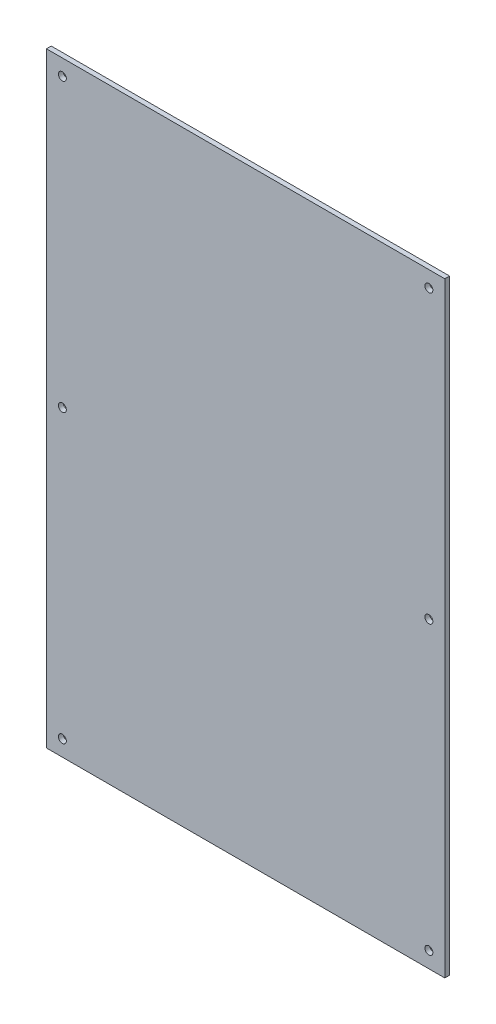
from build123d import *

# Parameters (mm, degrees)
ESQUISSE1_R        = 2.5
BOSS_EXTRU_1_DEPTH = 3


with BuildPart() as part:
    # Esquisse1 → Boss.-Extru.1 (new body)
    with BuildSketch(Plane.XY):
        Polygon((87.337784558, 66.147170972), (-35.162215442, 66.147170972), (-35.162215442, -313.852829028), (87.337784558, -313.852829028), (92.337784558, -313.852829028), (214.837784558, -313.852829028), (214.837784558, 66.147170972), (92.337784558, 66.147170972), align=None)
        with Locations((-25.162215442, 56.147170972)):
            Circle(ESQUISSE1_R, mode=Mode.SUBTRACT)
        with Locations((204.837784558, 56.147170972)):
            Circle(ESQUISSE1_R, mode=Mode.SUBTRACT)
        with Locations((204.837784558, -303.852829028)):
            Circle(ESQUISSE1_R, mode=Mode.SUBTRACT)
        with Locations((-25.162215442, -303.852829028)):
            Circle(ESQUISSE1_R, mode=Mode.SUBTRACT)
        with Locations((204.837784558, -123.852829028)):
            Circle(ESQUISSE1_R, mode=Mode.SUBTRACT)
        with Locations((-25.162215442, -123.852829028)):
            Circle(ESQUISSE1_R, mode=Mode.SUBTRACT)
    extrude(amount=BOSS_EXTRU_1_DEPTH)


solid = part.part
